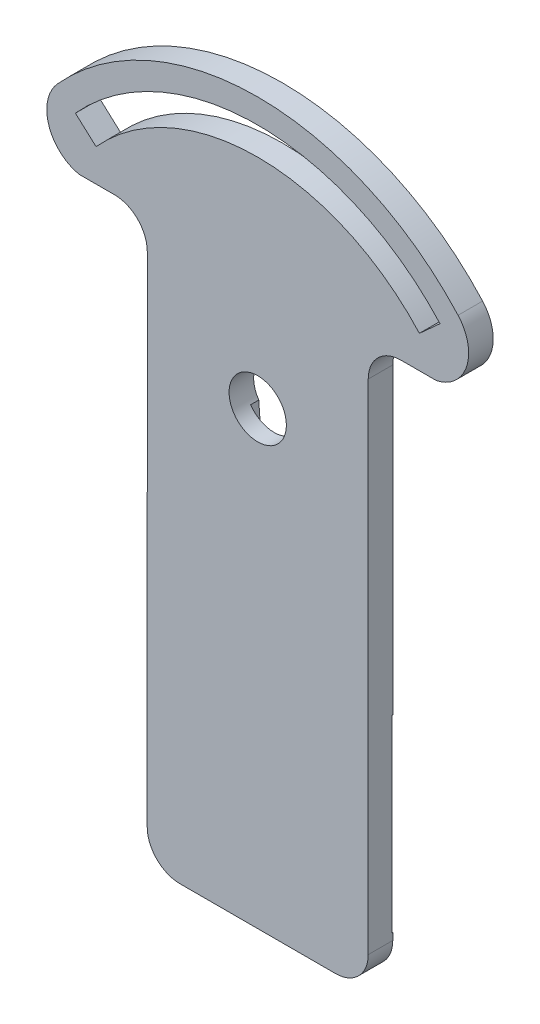
from build123d import *

# Parameters (mm, degrees)
CORTE_EXTERIOR_R        = 3.500002593
SALIENTE_EXTRUIR1_DEPTH = 3
CORTAR_EXTRUIR1_DEPTH   = 1
CORTAR_EXTRUIR2_DEPTH   = 0.1


with BuildPart() as part:
    # Corte exterior → Saliente-Extruir1 (new body)
    with BuildSketch(Plane.XY):
        with BuildLine():
            Line((47.504320945, 38.211786495), (51.847305041, 38.211786495))
            ThreePointArc((51.847305041, 38.211786495), (55.534254627, 41.572373104), (54.480090972, 46.448424641))
            ThreePointArc((54.480090972, 46.448424641), (30.004320476, 57.31391234), (5.528550918, 46.448424641))
            ThreePointArc((5.528550918, 46.448424641), (4.474387263, 41.572373104), (8.161336848, 38.211786495))
            Line((8.161336848, 38.211786495), (12.511035037, 38.211786495))
            ThreePointArc((12.511035037, 38.211786495), (15.339462162, 37.04021362), (16.511035037, 34.211786495))
            Line((16.511035037, 34.211786495), (16.504320945, -26.686088981))
            ThreePointArc((16.504320945, -26.686088981), (17.67589382, -29.514516106), (20.504320945, -30.686088981))
            Line((20.504320945, -30.686088981), (39.504320945, -30.686088981))
            ThreePointArc((39.504320945, -30.686088981), (42.33274807, -29.514516106), (43.504320945, -26.686088981))
            Line((43.504320945, -26.686088981), (43.504320945, 34.211786495))
            ThreePointArc((43.504320945, 34.211786495), (44.67589382, 37.04021362), (47.504320945, 38.211786495))
        make_face()
        with Locations((30.00431952, 24.313911283)):
            Circle(CORTE_EXTERIOR_R, mode=Mode.SUBTRACT)
        with BuildLine():
            ThreePointArc((52.277272453, 44.456319148), (30.004320476, 54.343913397), (7.731367869, 44.456320565))
            Line((7.731367869, 44.456320565), (10.253113799, 42.175794866))
            ThreePointArc((10.253113799, 42.175794866), (30.004320476, 50.943913397), (49.755526523, 42.175793449))
            Line((49.755526523, 42.175793449), (52.277272453, 44.456319148))
        make_face(mode=Mode.SUBTRACT)
    extrude(amount=SALIENTE_EXTRUIR1_DEPTH)

    # Grabado Superficie → Cortar-Extruir1 (cut)
    with BuildSketch(Plane.XY):
        with BuildLine():
            Line((32.873672963, 22.309708905), (31.999357171, 9.92309063))
            ThreePointArc((31.999357171, 9.92309063), (30.004320945, 8.063911283), (28.009284719, 9.92309063))
            Line((28.009284719, 9.92309063), (27.134968927, 22.309708905))
            ThreePointArc((27.134968927, 22.309708905), (30.004320945, 20.813910115), (32.873672963, 22.309708905))
        make_face()
    extrude(amount=CORTAR_EXTRUIR1_DEPTH, mode=Mode.SUBTRACT)

    # grabado linea medio → Cortar-Extruir2 (cut)
    with BuildSketch(Plane.XY):
        Polygon((16.504320945, -26.046088981), (24.644320945, -26.046088981), (24.644320945, -30.686088981), (27.164320945, -30.686088981), (27.164320945, -26.044872481), (43.504320945, -25.844872481), (43.504320945, -2.816088981), (27.164320945, -2.816088981), (27.164320945, 1.823911019), (24.644320945, 1.823911019), (24.644320945, -2.816088981), (20.584320945, -2.816088981), (20.584320945, -10.896088981), (16.504320945, -10.896088981), align=None)
    extrude(amount=CORTAR_EXTRUIR2_DEPTH, mode=Mode.SUBTRACT)


solid = part.part
